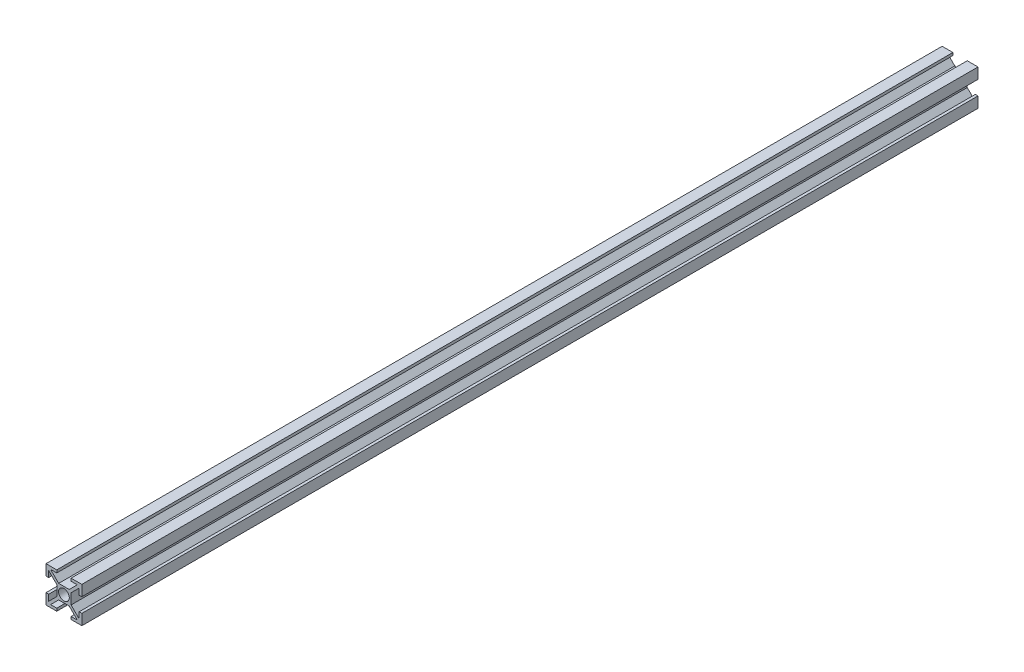
from build123d import *

# Parameters (mm, degrees)
ESBO_O1_R                = 3
RESSALTO_EXTRUS_O1_DEPTH = 500


with BuildPart() as part:
    # Esboço1 → Ressalto-extrusão1 (new body)
    with BuildSketch(Plane.XY):
        Polygon((-2.939339828, 4), (2.939339828, 4), (7.439339828, 8.5), (4, 8.5), (4, 10), (10, 10), (10, 4), (8.5, 4), (8.5, 7.439339828), (4, 2.939339828), (4, -2.939339828), (8.5, -7.439339828), (8.5, -4), (10, -4), (10, -10), (4, -10), (4, -8.5), (7.439339828, -8.5), (2.939339828, -4), (-2.939339828, -4), (-7.439339828, -8.5), (-4, -8.5), (-4, -10), (-10, -10), (-10, -4), (-8.5, -4), (-8.5, -7.439339828), (-4, -2.939339828), (-4, 2.939339828), (-8.5, 7.439339828), (-8.5, 4), (-10, 4), (-10, 10), (-4, 10), (-4, 8.5), (-7.439339828, 8.5), align=None)
        Circle(ESBO_O1_R, mode=Mode.SUBTRACT)
    extrude(amount=RESSALTO_EXTRUS_O1_DEPTH)


solid = part.part
